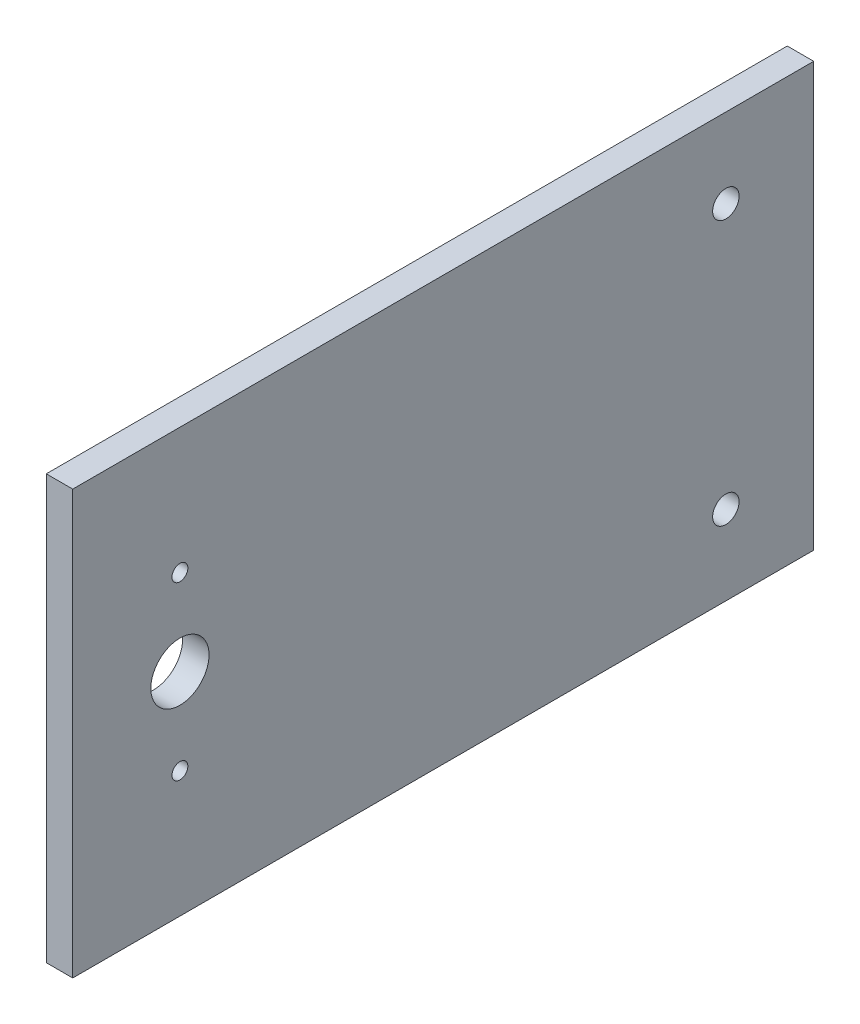
from build123d import *

# Parameters (mm, degrees)
SKETCH1_W           = 80
SKETCH1_H           = 140
SKETCH1_R           = 5.5
SKETCH1_R_2         = 1.5
SKETCH1_R_3         = 2.5
BOSS_EXTRUDE1_DEPTH = 5


with BuildPart() as part:
    # Sketch1 → Boss-Extrude1 (new body)
    with BuildSketch(Plane.YZ):
        Rectangle(SKETCH1_W, SKETCH1_H)
        with Locations((0, 49.75)):
            Circle(SKETCH1_R, mode=Mode.SUBTRACT)
        with Locations((-16.22, 49.75)):
            Circle(SKETCH1_R_2, mode=Mode.SUBTRACT)
        with Locations((16.22, 49.75)):
            Circle(SKETCH1_R_2, mode=Mode.SUBTRACT)
        with Locations((-25, -53.4)):
            Circle(SKETCH1_R_3, mode=Mode.SUBTRACT)
        with Locations((25, -53.4)):
            Circle(SKETCH1_R_3, mode=Mode.SUBTRACT)
    extrude(amount=BOSS_EXTRUDE1_DEPTH)


solid = part.part
